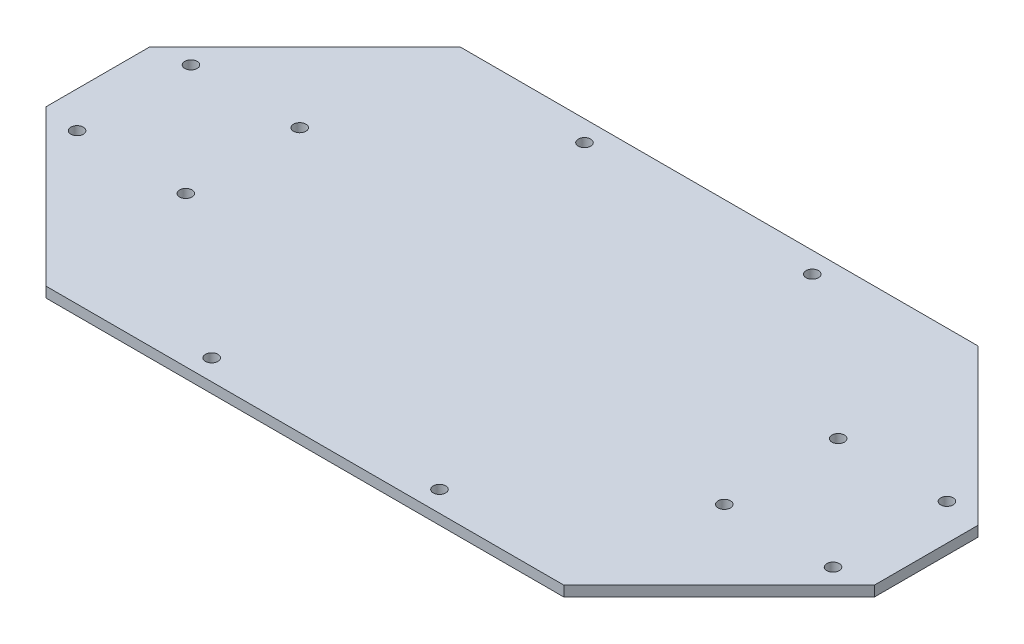
from build123d import *

# Parameters (mm, degrees)
ESQUISSE1_W             = 160
ESQUISSE1_H             = 80
BOSS_EXTRU_1_DEPTH      = 2
ENL_V_MAT_EXTRU_1_DEPTH = 2
D_GAGEMENT_M21_D        = 2.4


with BuildPart() as part:
    # Esquisse1 → Boss.-Extru.1 (new body)
    with BuildSketch(Plane(origin=(0, 0, 0), x_dir=(1, 0, 0), z_dir=(0, 1, 0))):
        with Locations((80, 40)):
            Rectangle(ESQUISSE1_W, ESQUISSE1_H)
    extrude(amount=BOSS_EXTRU_1_DEPTH)

    # Esquisse2 → Enlèv. mat.-Extru.1 (cut)
    with BuildSketch(Plane(origin=(0, 2, 0), x_dir=(1, 0, 0), z_dir=(0, 1, 0))):
        Polygon((0, 30), (30, 0), (0, 0), align=None)
        Polygon((30, 80), (0, 50), (0, 80), align=None)
        Polygon((130, 80), (160, 80), (160, 50), align=None)
        Polygon((160, 30), (130, 0), (160, 0), align=None)
    extrude(amount=-ENL_V_MAT_EXTRU_1_DEPTH, mode=Mode.SUBTRACT)

    # Dégagement M21 (through all)
    with Locations(Plane(origin=(0, 2, 0), x_dir=(1, 0, 0), z_dir=(0, 1, 0))):
        with Locations((7, 51), (7, 29), (28, 29), (28, 51), (58, 76), (58, 4), (132, 29), (153, 29), (153, 51), (132, 51), (101.994988581, 76), (101.994988581, 4)):
            Hole(D_GAGEMENT_M21_D / 2)


solid = part.part
